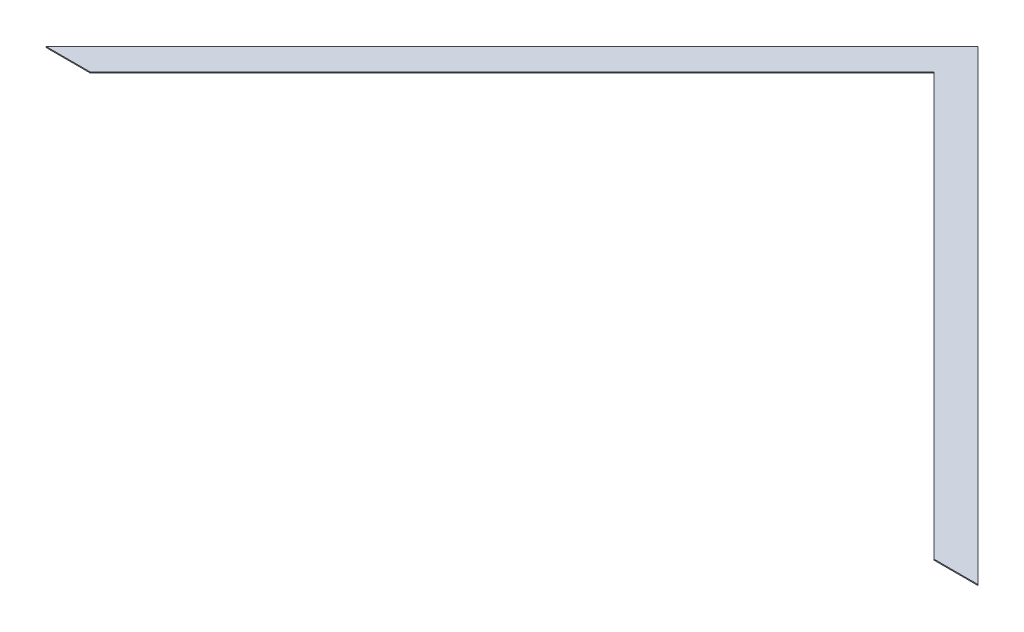
from build123d import *

# Parameters (mm, degrees)
BOSS_EXTRUDE1_DEPTH = 1.5875


with BuildPart() as part:
    # Sketch1 → Boss-Extrude1 (new body)
    with BuildSketch(Plane(origin=(0, 0, 0), x_dir=(1, 0, 0), z_dir=(0, 1, 0))):
        Polygon((0, 0), (762, 762), (1524, 0), (1452.157951031, 0), (762, 690.157951031), (71.842048969, 0), align=None)
    extrude(amount=BOSS_EXTRUDE1_DEPTH)


solid = part.part
